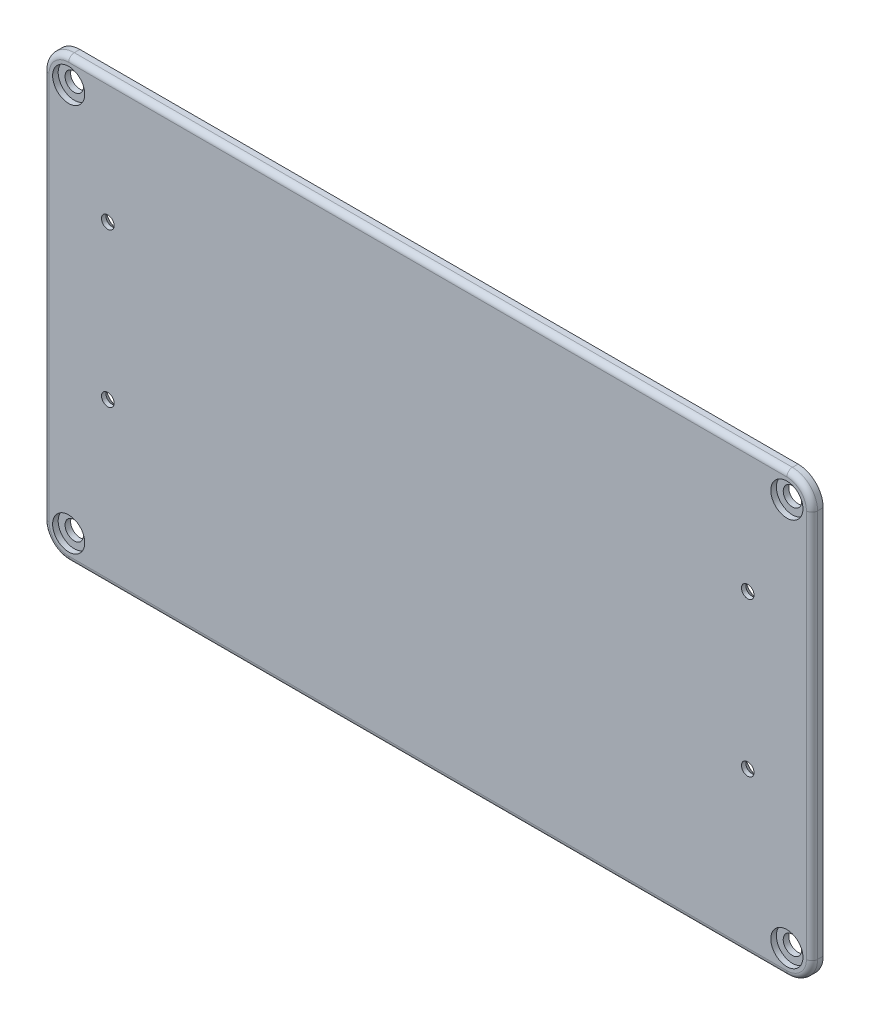
from build123d import *

# Parameters (mm, degrees)
ESQUISSE4_W                                      = 275
ESQUISSE4_H                                      = 157
BOSS_EXTRU_2_DEPTH                               = 4
FRAISAGE_POUR_VIS_T_TE_FRAIS_E_M42_AT_COUNT      = 2
FRAISAGE_POUR_VIS_T_TE_FRAIS_E_M42_AT_PITCH      = 235.512207752
FRAISAGE_POUR_VIS_T_TE_FRAIS_E_M42_2_COUNT       = 2
FRAISAGE_POUR_VIS_T_TE_FRAIS_E_M42_2_PITCH       = 229
FRAISAGE_POUR_VIS_T_TE_FRAIS_E_M42_3_COUNT       = 2
FRAISAGE_POUR_VIS_T_TE_FRAIS_E_M42_3_PITCH       = 55
CHAMBRAGE_POUR_VIS_T_TE_RONDE_6_PANS_D           = 6.6
CHAMBRAGE_POUR_VIS_T_TE_RONDE_6_PANS_CBORE_D     = 11.5
CHAMBRAGE_POUR_VIS_T_TE_RONDE_6_PANS_CBORE_DEPTH = 2
CONG_1_R                                         = 9
CONG_2_R                                         = 2


with BuildPart() as part:
    # Esquisse4 → Boss.-Extru.2 (new body)
    with BuildSketch(Plane.XY):
        Rectangle(ESQUISSE4_W, ESQUISSE4_H)
    extrude(amount=BOSS_EXTRU_2_DEPTH)

    # Esquisse6 → Fraisage pour vis à tête fraisée M42 (revolve, cut)
    with BuildSketch(Plane(origin=(-114.5, -21, 0), x_dir=(0, 1, 0), z_dir=(1, 0, 0))):
        Polygon((0, 0), (0, 4), (2.25, 4), (2.25, 2.45), (4.7, 0), align=None)
    fraisage_pour_vis_t_te_frais_e_m42 = revolve(axis=Axis((-114.5, -21, -6.35), (0, 0, 1)), mode=Mode.SUBTRACT)

    # Fraisage pour vis à tête fraisée M42 at: Fraisage pour vis à tête fraisée M42 ×2
    with Locations(*[Vector(0.972348747, 0.233533542, 0) * (i * FRAISAGE_POUR_VIS_T_TE_FRAIS_E_M42_AT_PITCH) for i in range(1, FRAISAGE_POUR_VIS_T_TE_FRAIS_E_M42_AT_COUNT)]):
        add(fraisage_pour_vis_t_te_frais_e_m42, mode=Mode.SUBTRACT)

    # Fraisage pour vis _ t_te frais_e M42 2: Fraisage pour vis à tête fraisée M42 ×2
    with Locations(*[(i * FRAISAGE_POUR_VIS_T_TE_FRAIS_E_M42_2_PITCH, 0, 0) for i in range(1, FRAISAGE_POUR_VIS_T_TE_FRAIS_E_M42_2_COUNT)]):
        add(fraisage_pour_vis_t_te_frais_e_m42, mode=Mode.SUBTRACT)

    # Fraisage pour vis _ t_te frais_e M42 3: Fraisage pour vis à tête fraisée M42 ×2
    with Locations(*[(0, i * FRAISAGE_POUR_VIS_T_TE_FRAIS_E_M42_3_PITCH, 0) for i in range(1, FRAISAGE_POUR_VIS_T_TE_FRAIS_E_M42_3_COUNT)]):
        add(fraisage_pour_vis_t_te_frais_e_m42, mode=Mode.SUBTRACT)

    # Chambrage pour Vis à tête ronde à 6 pans creux M61 (through all)
    with Locations(Plane.XY.offset(4)):
        with Locations((128.5, -69.5), (-128.5, -69.5), (-128.5, 69.5), (128.5, 69.5)):
            CounterBoreHole(CHAMBRAGE_POUR_VIS_T_TE_RONDE_6_PANS_D / 2, CHAMBRAGE_POUR_VIS_T_TE_RONDE_6_PANS_CBORE_D / 2, CHAMBRAGE_POUR_VIS_T_TE_RONDE_6_PANS_CBORE_DEPTH)

    # Congé1
    cong_1_edges = [part.edges().sort_by_distance(p)[0] for p in [
        (137.5, 78.5, 2),
        (137.5, -78.5, 2),
        (-137.5, -78.5, 2),
        (-137.5, 78.5, 2),
    ]]
    fillet(cong_1_edges, radius=CONG_1_R)

    # Congé2
    cong_2_edges = [part.edges().sort_by_distance(p)[0] for p in [
        (0, 78.5, 4),
        (137.5, 0, 4),
        (-137.5, 0, 4),
        (0, -78.5, 4),
        (-134.863961031, -75.863961031, 4),
        (-134.863961031, 75.863961031, 4),
        (134.863961031, -75.863961031, 4),
        (134.863961031, 75.863961031, 4),
    ]]
    fillet(cong_2_edges, radius=CONG_2_R)


solid = part.part
